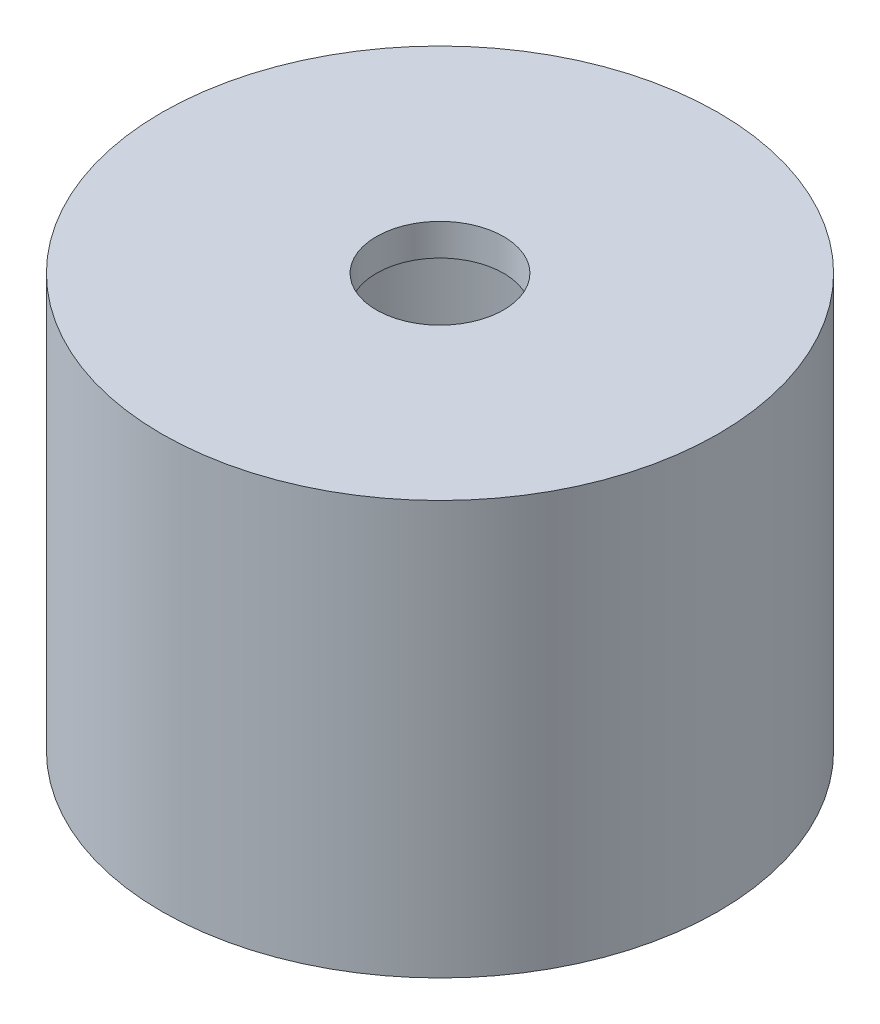
from build123d import *

# Parameters (mm, degrees)
EXTRUSION1_REACH = 19.5
ESQUISSE2_R      = 2


with BuildPart() as part:
    # Esquisse1 → Révolution1 (revolve)
    with BuildSketch(Plane.XY):
        Polygon((-17.5, 5), (-4, 5), (-4, 3), (-11, 3), (-11, -21), (-17.5, -21), align=None)
    revolve(axis=Axis((0, 0, 0), (0, -1, 0)))

    # Esquisse2 → Extrusion1 (cut, up to next)
    with BuildSketch(Plane(origin=(0, 0, 0), x_dir=(0, 0, -1), z_dir=(1, 0, 0)), mode=Mode.PRIVATE) as extrusion1_sk1:
        with Locations((0, -13.5)):
            Circle(ESQUISSE2_R)
    extrusion1_tool1 = extrude(extrusion1_sk1.sketch, amount=-EXTRUSION1_REACH, mode=Mode.PRIVATE) & part.part
    add(extrusion1_tool1.solids().sort_by_distance((0, -13.5, 0))[0], mode=Mode.SUBTRACT)


solid = part.part
